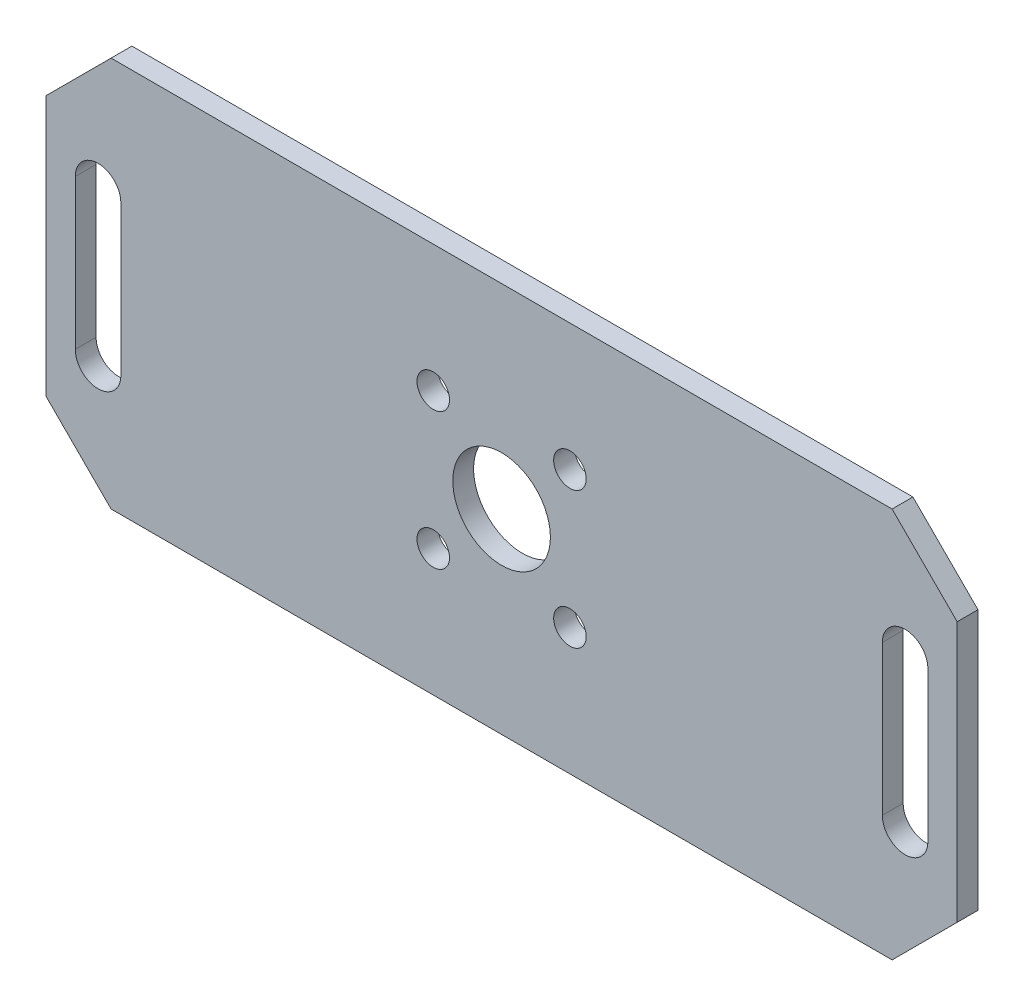
from build123d import *

# Parameters (mm, degrees)
SKETCH1_W           = 140
SKETCH1_H           = 60
SKETCH1_R           = 7.5
SKETCH1_R_2         = 2.5
BOSS_EXTRUDE1_DEPTH = 3.2
CHAMFER1_SIZE       = 10


with BuildPart() as part:
    # Sketch1 → Boss-Extrude1 (new body)
    with BuildSketch(Plane.XY):
        Rectangle(SKETCH1_W, SKETCH1_H)
        Circle(SKETCH1_R, mode=Mode.SUBTRACT)
        with Locations((-10.5, 10.5)):
            Circle(SKETCH1_R_2, mode=Mode.SUBTRACT)
        with Locations((10.5, 10.5)):
            Circle(SKETCH1_R_2, mode=Mode.SUBTRACT)
        with Locations((10.5, -10.5)):
            Circle(SKETCH1_R_2, mode=Mode.SUBTRACT)
        with Locations((-10.5, -10.5)):
            Circle(SKETCH1_R_2, mode=Mode.SUBTRACT)
        with BuildLine():
            Line((-65.5, -11.5), (-65.5, 11.5))
            ThreePointArc((-65.5, 11.5), (-62, 15), (-58.5, 11.5))
            Line((-58.5, 11.5), (-58.5, -11.5))
            ThreePointArc((-58.5, -11.5), (-62, -15), (-65.5, -11.5))
        make_face(mode=Mode.SUBTRACT)
        with BuildLine():
            Line((58.5, -11.5), (58.5, 11.5))
            ThreePointArc((58.5, 11.5), (62, 15), (65.5, 11.5))
            Line((65.5, 11.5), (65.5, -11.5))
            ThreePointArc((65.5, -11.5), (62, -15), (58.5, -11.5))
        make_face(mode=Mode.SUBTRACT)
    extrude(amount=BOSS_EXTRUDE1_DEPTH)

    # Chamfer1
    chamfer1_edges = [part.edges().sort_by_distance(p)[0] for p in [
        (70, -30, 1.6),
        (-70, -30, 1.6),
        (-70, 30, 1.6),
        (70, 30, 1.6),
    ]]
    chamfer(chamfer1_edges, length=CHAMFER1_SIZE)


solid = part.part
